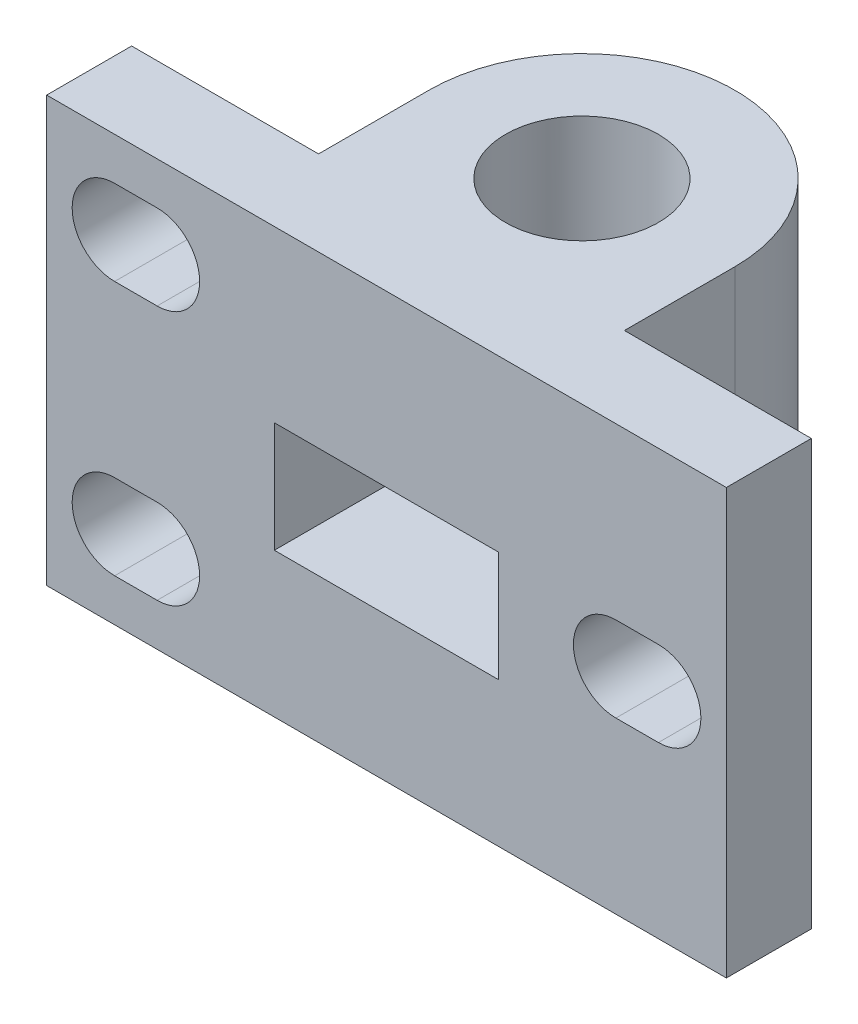
from build123d import *

# Parameters (mm, degrees)
SKETCH1_R           = 4.5
BOSS_EXTRUDE1_DEPTH = 25
CUT_EXTRUDE1_DEPTH  = 6.5
SKETCH4_W           = 13.2
SKETCH4_H           = 6.5
CUT_EXTRUDE2_DEPTH  = 8.689488223
CUT_EXTRUDE3_DEPTH  = 6


with BuildPart() as part:
    # Sketch1 → Boss-Extrude1 (new body)
    with BuildSketch(Plane(origin=(0, 0, 0), x_dir=(1, 0, 0), z_dir=(0, 1, 0))):
        with BuildLine():
            Line((20, 0), (-20, 0))
            Line((-20, 0), (-20, 5))
            Line((-20, 5), (-9, 5))
            Line((-9, 5), (-9, 11.5))
            ThreePointArc((-9, 11.5), (0, 20.5), (9, 11.5))
            Line((9, 11.5), (9, 5))
            Line((9, 5), (20, 5))
            Line((20, 5), (20, 0))
        make_face()
        with Locations((0, 11.5)):
            Circle(SKETCH1_R, mode=Mode.SUBTRACT)
    extrude(amount=BOSS_EXTRUDE1_DEPTH)

    # Sketch2 → Cut-Extrude1 (cut)
    with BuildSketch(Plane(origin=(0, 15, 0), x_dir=(1, 0, 0), z_dir=(0, 1, 0))):
        Polygon((0, 19.121023553), (-6.6, 15.310511777), (-6.6, 7.689488223), (0, 3.878976447), (6.6, 7.689488223), (6.6, 15.310511777), align=None)
    extrude(amount=-CUT_EXTRUDE1_DEPTH, mode=Mode.SUBTRACT)

    # Sketch4 → Cut-Extrude2 (cut, through all)
    with BuildSketch(Plane(origin=(0, 0, -7.689488223), x_dir=(-1, 0, 0), z_dir=(0, 0, -1))):
        with Locations((0, 11.75)):
            Rectangle(SKETCH4_W, SKETCH4_H)
    extrude(amount=-CUT_EXTRUDE2_DEPTH, mode=Mode.SUBTRACT)

    # Sketch5 → Cut-Extrude3 (cut, through all)
    with BuildSketch(Plane(origin=(0, 0, -5), x_dir=(-1, 0, 0), z_dir=(0, 0, -1))):
        with BuildLine():
            Line((-16, 15), (-13.5, 15))
            ThreePointArc((-13.5, 15), (-11, 12.5), (-13.5, 10))
            Line((-13.5, 10), (-16, 10))
            ThreePointArc((-16, 10), (-18.5, 12.5), (-16, 15))
        make_face()
        with BuildLine():
            Line((13.5, 22.5), (16, 22.5))
            ThreePointArc((16, 22.5), (18.5, 20), (16, 17.5))
            Line((16, 17.5), (13.5, 17.5))
            ThreePointArc((13.5, 17.5), (11, 20), (13.5, 22.5))
        make_face()
        with BuildLine():
            Line((13.5, 7.5), (16, 7.5))
            ThreePointArc((16, 7.5), (18.5, 5), (16, 2.5))
            Line((16, 2.5), (13.5, 2.5))
            ThreePointArc((13.5, 2.5), (11, 5), (13.5, 7.5))
        make_face()
    extrude(amount=-CUT_EXTRUDE3_DEPTH, mode=Mode.SUBTRACT)


solid = part.part
